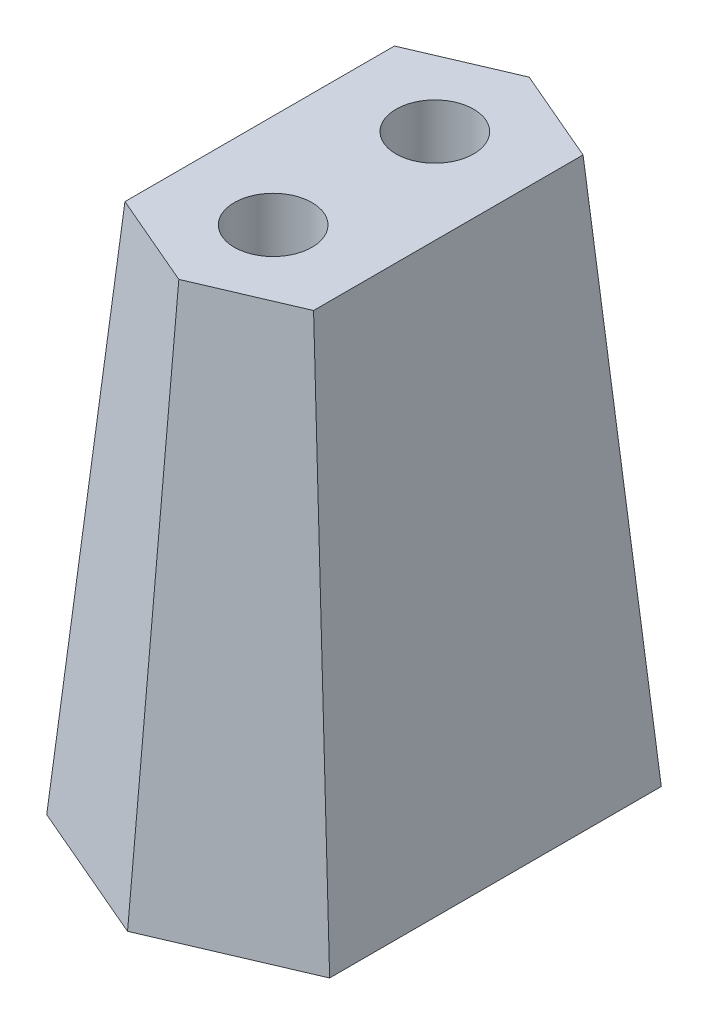
from build123d import *

# Parameters (mm, degrees)
BOSS_EXTRUDE1_DEPTH = 20
SKETCH2_R           = 1.44
CUT_EXTRUDE1_DEPTH  = 22.319005605
DRAFT1_ANGLE        = 5
CUT_EXTRUDE2_DEPTH  = 5
DRAFT2_ANGLE        = 10


with BuildPart() as part:
    # Sketch1 → Boss-Extrude1 (new body)
    with BuildSketch(Plane(origin=(0, 0, 0), x_dir=(1, 0, 0), z_dir=(0, 1, 0))):
        Polygon((3.5, -5), (3.5, 5), (0, 6.5), (-3.5, 5), (-3.5, -5), (0, -6.5), align=None)
    extrude(amount=BOSS_EXTRUDE1_DEPTH)

    # Sketch2 → Cut-Extrude1 (cut, through all)
    with BuildSketch(Plane(origin=(0, 20, 0), x_dir=(1, 0, 0), z_dir=(0, 1, 0))):
        with Locations((0, 3)):
            Circle(SKETCH2_R)
        with Locations((0, -3)):
            Circle(SKETCH2_R)
    extrude(amount=-CUT_EXTRUDE1_DEPTH, mode=Mode.SUBTRACT)

    # Draft1
    draft1_faces = [part.faces().sort_by_distance(p)[0] for p in [
        (-3.5, 10, 0),
        (-1.75, 10, -5.75),
        (1.75, 10, -5.75),
        (3.5, 10, 0),
        (1.75, 10, 5.75),
        (-1.75, 10, 5.75),
    ]]
    draft(draft1_faces, Plane.ZX.offset(20), DRAFT1_ANGLE)

    # Sketch1_2 → Cut-Extrude2 (cut)
    with BuildSketch(Plane(origin=(0, 0, 0), x_dir=(1, 0, 0), z_dir=(0, 1, 0))):
        Polygon((3.5, -5), (3.5, 5), (0, 6.5), (-3.5, 5), (-3.5, -5), (0, -6.5), align=None)
    extrude(amount=CUT_EXTRUDE2_DEPTH, mode=Mode.SUBTRACT)

    # Draft2
    draft2_faces = [part.faces().sort_by_distance(p)[0] for p in [
        (-3.5, 2.5, 0),
        (-1.75, 2.5, 5.75),
        (1.75, 2.5, 5.75),
        (3.5, 2.5, 0),
        (1.75, 2.5, -5.75),
        (-1.75, 2.5, -5.75),
    ]]
    draft(draft2_faces, Plane(origin=(0, 5, 0), x_dir=(0, 0, -1), z_dir=(0, -1, 0)), DRAFT2_ANGLE)


solid = part.part
